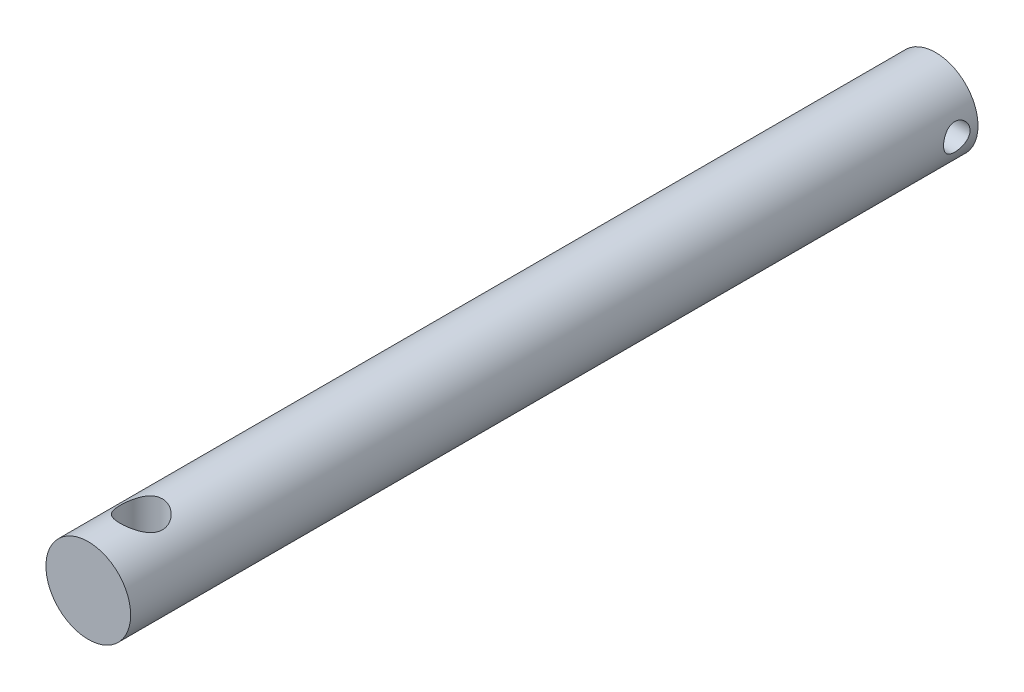
from build123d import *

# Parameters (mm, degrees)
SKETCH_1_R               = 8
EXTRUDE_1_DEPTH          = 160
CUT_EXTRUDE_1_DEPTH      = 120
CUT_EXTRUDE_1_DEPTH_BACK = 120
SKETCH_2_R               = 4
SKETCH_3_R               = 2.5
CUT_EXTRUDE_2_DEPTH      = 10


with BuildPart() as part:
    # 草图1 → 凸台-拉伸1 (new body)
    with BuildSketch(Plane.XY):
        Circle(SKETCH_1_R)
    extrude(amount=EXTRUDE_1_DEPTH)

    # 草图2 → 切除-拉伸1 (cut, two sides: drawn at the far end of the back side and taken through both)
    with BuildSketch(Plane(origin=(0, 0, 0), x_dir=(1, 0, 0), z_dir=(0, 1, 0)).offset(-CUT_EXTRUDE_1_DEPTH_BACK)):
        with Locations((0, -150)):
            Circle(SKETCH_2_R)
    extrude(amount=CUT_EXTRUDE_1_DEPTH + CUT_EXTRUDE_1_DEPTH_BACK, mode=Mode.SUBTRACT)

    # 草图3 → 切除-拉伸2 (cut)
    with BuildSketch(Plane(origin=(0, 0, 0), x_dir=(0, 0, -1), z_dir=(1, 0, 0))):
        with Locations((-4, 0)):
            Circle(SKETCH_3_R)
    extrude(amount=CUT_EXTRUDE_2_DEPTH, mode=Mode.SUBTRACT)


solid = part.part
